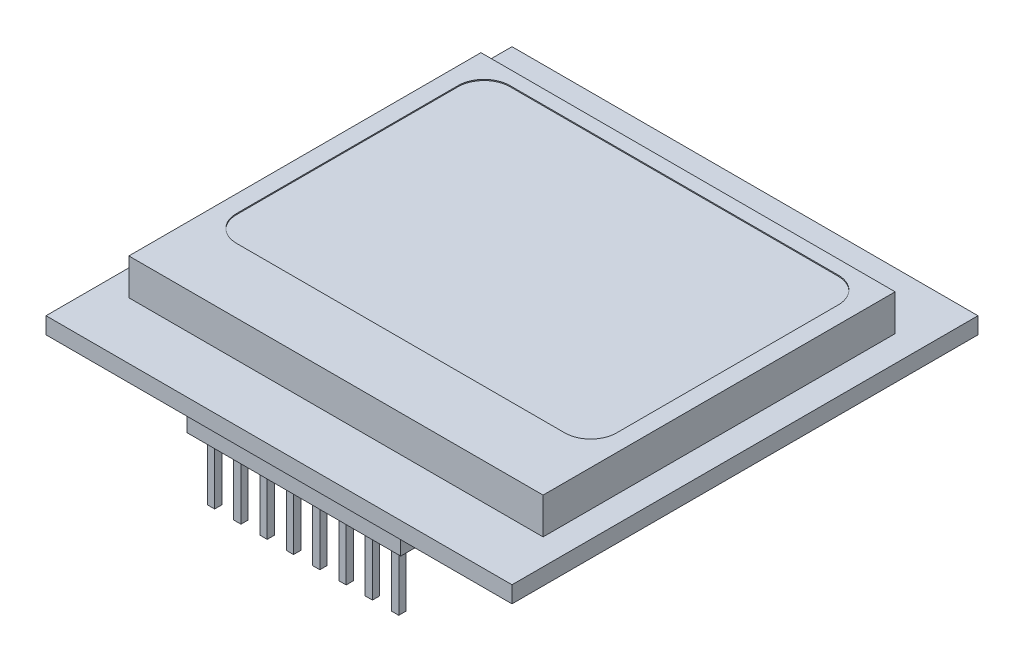
from build123d import *

# Parameters (mm, degrees)
SKETCH1_W           = 45
SKETCH1_H           = 45
BOSS_EXTRUDE1_DEPTH = 1.6
SKETCH2_W           = 40
SKETCH2_H           = 34
BOSS_EXTRUDE2_DEPTH = 3.5
SKETCH4_W           = 20.66
SKETCH4_H           = 2.5
BOSS_EXTRUDE3_DEPTH = 2.8
SKETCH5_W           = 0.7
SKETCH5_H           = 0.7
BOSS_EXTRUDE4_DEPTH = 5.95
CUT_EXTRUDE1_DEPTH  = 0.1


with BuildPart() as part:
    # Sketch1 → Boss-Extrude1 (new body)
    with BuildSketch(Plane(origin=(0, 0, 0), x_dir=(1, 0, 0), z_dir=(0, 1, 0))):
        Rectangle(SKETCH1_W, SKETCH1_H)
    extrude(amount=BOSS_EXTRUDE1_DEPTH)

    # Sketch2 → Boss-Extrude2 (add)
    with BuildSketch(Plane(origin=(0, 1.6, 0), x_dir=(1, 0, 0), z_dir=(0, 1, 0))):
        Rectangle(SKETCH2_W, SKETCH2_H)
    extrude(amount=BOSS_EXTRUDE2_DEPTH)

    # Sketch4 → Boss-Extrude3 (add)
    with BuildSketch(Plane.XZ):
        with Locations((0, 19.825)):
            Rectangle(SKETCH4_W, SKETCH4_H)
    boss_extrude3 = extrude(amount=BOSS_EXTRUDE3_DEPTH)

    # Sketch5 → Boss-Extrude4 (add)
    with BuildSketch(Plane.XZ.offset(2.8)):
        with Locations((-8.89, 19.825)):
            Rectangle(SKETCH5_W, SKETCH5_H)
        with Locations((-6.35, 19.825)):
            Rectangle(SKETCH5_W, SKETCH5_H)
        with Locations((-3.81, 19.825)):
            Rectangle(SKETCH5_W, SKETCH5_H)
        with Locations((-1.27, 19.825)):
            Rectangle(SKETCH5_W, SKETCH5_H)
        with Locations((1.27, 19.825)):
            Rectangle(SKETCH5_W, SKETCH5_H)
        with Locations((3.81, 19.825)):
            Rectangle(SKETCH5_W, SKETCH5_H)
        with Locations((6.35, 19.825)):
            Rectangle(SKETCH5_W, SKETCH5_H)
        with Locations((8.89, 19.825)):
            Rectangle(SKETCH5_W, SKETCH5_H)
    boss_extrude4 = extrude(amount=BOSS_EXTRUDE4_DEPTH)

    # Sketch6 → Cut-Extrude1 (cut)
    with BuildSketch(Plane(origin=(0, 5.1, 0), x_dir=(1, 0, 0), z_dir=(0, 1, 0))):
        with BuildLine():
            Line((-15.85, 15.65), (15.85, 15.65))
            ThreePointArc((15.85, 15.65), (17.617766953, 14.917766953), (18.35, 13.15))
            Line((18.35, 13.15), (18.35, -8.25))
            ThreePointArc((18.35, -8.25), (17.617766953, -10.017766953), (15.85, -10.75))
            Line((15.85, -10.75), (-15.85, -10.75))
            ThreePointArc((-15.85, -10.75), (-17.617766953, -10.017766953), (-18.35, -8.25))
            Line((-18.35, -8.25), (-18.35, 13.15))
            ThreePointArc((-18.35, 13.15), (-17.617766953, 14.917766953), (-15.85, 15.65))
        make_face()
    extrude(amount=-CUT_EXTRUDE1_DEPTH, mode=Mode.SUBTRACT)

    # Mirror1: Boss-Extrude3, Boss-Extrude4 across plane
    add(boss_extrude3.mirror(Plane.XY))
    add(boss_extrude4.mirror(Plane.XY))


solid = part.part
